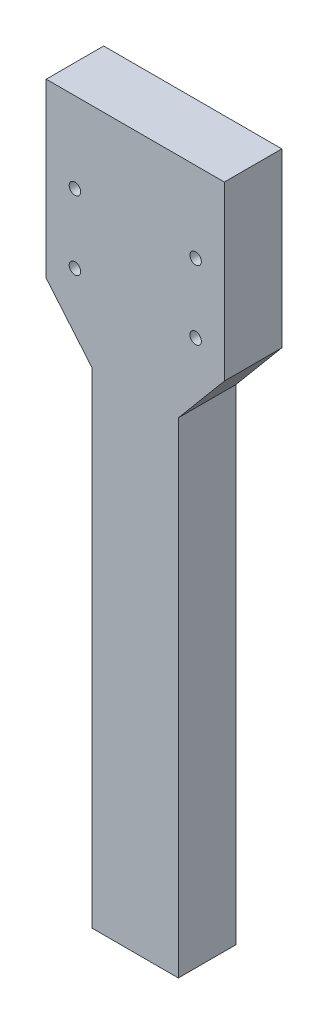
from build123d import *

# Parameters (mm, degrees)
SKETCH1_R           = 1
BOSS_EXTRUDE1_DEPTH = 10


with BuildPart() as part:
    # Sketch1 → Boss-Extrude1 (new body)
    with BuildSketch(Plane.XY):
        Polygon((15, 84.425971259), (23, 93.96), (23, 123.96), (15, 123.96), (0, 123.96), (-8, 123.96), (-8, 93.96), (0, 84.425971259), (0, 0), (15, 0), align=None)
        with Locations((-3, 109.96)):
            Circle(SKETCH1_R, mode=Mode.SUBTRACT)
        with Locations((-3, 97.96)):
            Circle(SKETCH1_R, mode=Mode.SUBTRACT)
        with Locations((18, 97.96)):
            Circle(SKETCH1_R, mode=Mode.SUBTRACT)
        with Locations((18, 109.96)):
            Circle(SKETCH1_R, mode=Mode.SUBTRACT)
    extrude(amount=BOSS_EXTRUDE1_DEPTH)


solid = part.part
